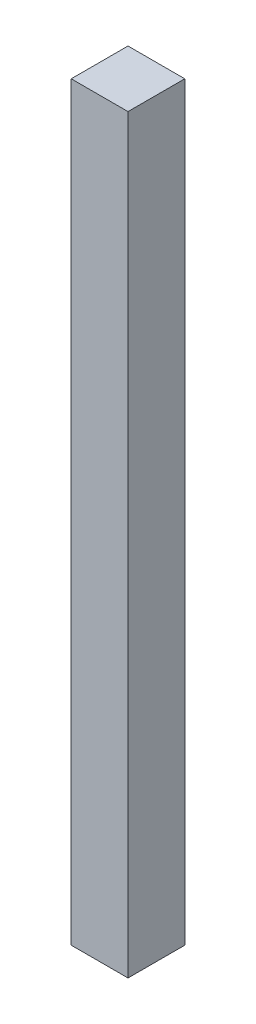
from build123d import *

# Parameters (mm, degrees)
SKETCH1_W           = 88.9
SKETCH1_H           = 88.9
BOSS_EXTRUDE1_DEPTH = 1174.75


with BuildPart() as part:
    # Sketch1 → Boss-Extrude1 (new body)
    with BuildSketch(Plane(origin=(0, 0, 0), x_dir=(1, 0, 0), z_dir=(0, 1, 0))):
        with Locations((-44.45, 44.45)):
            Rectangle(SKETCH1_W, SKETCH1_H)
    extrude(amount=BOSS_EXTRUDE1_DEPTH)


solid = part.part
